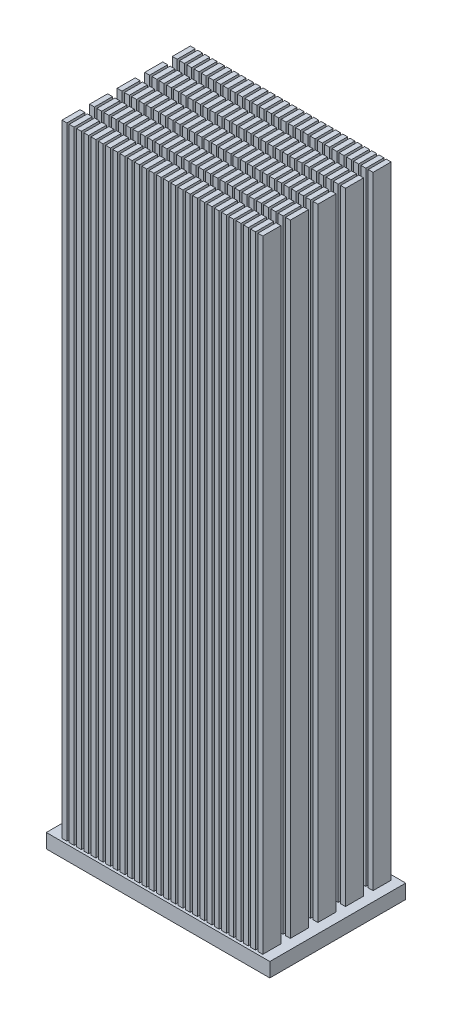
from build123d import *

# Parameters (mm, degrees)
SKETCH1_W           = 78.24
SKETCH1_H           = 47.57
BOSS_EXTRUDE1_DEPTH = 5
SKETCH2_W           = 1.704022388
SKETCH2_H           = 6.329226012
BOSS_EXTRUDE2_DEPTH = 222.758


with BuildPart() as part:
    # Sketch1 → Boss-Extrude1 (new body)
    with BuildSketch(Plane(origin=(0, 0, 0), x_dir=(1, 0, 0), z_dir=(0, 1, 0))):
        Rectangle(SKETCH1_W, SKETCH1_H)
    extrude(amount=BOSS_EXTRUDE1_DEPTH)

    # Sketch2 → Boss-Extrude2 (add)
    with BuildSketch(Plane(origin=(0, 0, 0), x_dir=(1, 0, 0), z_dir=(0, 1, 0))):
        with Locations((-33.715300105, 18.926820095)):
            Rectangle(SKETCH2_W, SKETCH2_H)
        with Locations((-31.175300105, 18.926820095)):
            Rectangle(SKETCH2_W, SKETCH2_H)
        with Locations((-28.635300105, 18.926820095)):
            Rectangle(SKETCH2_W, SKETCH2_H)
        with Locations((-26.095300105, 18.926820095)):
            Rectangle(SKETCH2_W, SKETCH2_H)
        with Locations((-23.555300105, 18.926820095)):
            Rectangle(SKETCH2_W, SKETCH2_H)
        with Locations((-21.015300105, 18.926820095)):
            Rectangle(SKETCH2_W, SKETCH2_H)
        with Locations((-18.475300105, 18.926820095)):
            Rectangle(SKETCH2_W, SKETCH2_H)
        with Locations((-15.935300105, 18.926820095)):
            Rectangle(SKETCH2_W, SKETCH2_H)
        with Locations((-13.395300105, 18.926820095)):
            Rectangle(SKETCH2_W, SKETCH2_H)
        with Locations((-10.855300105, 18.926820095)):
            Rectangle(SKETCH2_W, SKETCH2_H)
        with Locations((-8.315300105, 18.926820095)):
            Rectangle(SKETCH2_W, SKETCH2_H)
        with Locations((-5.775300105, 18.926820095)):
            Rectangle(SKETCH2_W, SKETCH2_H)
        with Locations((-3.235300105, 18.926820095)):
            Rectangle(SKETCH2_W, SKETCH2_H)
        with Locations((-0.695300105, 18.926820095)):
            Rectangle(SKETCH2_W, SKETCH2_H)
        with Locations((1.844699895, 18.926820095)):
            Rectangle(SKETCH2_W, SKETCH2_H)
        with Locations((4.384699895, 18.926820095)):
            Rectangle(SKETCH2_W, SKETCH2_H)
        with Locations((6.924699895, 18.926820095)):
            Rectangle(SKETCH2_W, SKETCH2_H)
        with Locations((9.464699895, 18.926820095)):
            Rectangle(SKETCH2_W, SKETCH2_H)
        with Locations((12.004699895, 18.926820095)):
            Rectangle(SKETCH2_W, SKETCH2_H)
        with Locations((14.544699895, 18.926820095)):
            Rectangle(SKETCH2_W, SKETCH2_H)
        with Locations((17.084699895, 18.926820095)):
            Rectangle(SKETCH2_W, SKETCH2_H)
        with Locations((19.624699895, 18.926820095)):
            Rectangle(SKETCH2_W, SKETCH2_H)
        with Locations((22.164699895, 18.926820095)):
            Rectangle(SKETCH2_W, SKETCH2_H)
        with Locations((24.704699895, 18.926820095)):
            Rectangle(SKETCH2_W, SKETCH2_H)
        with Locations((27.244699895, 18.926820095)):
            Rectangle(SKETCH2_W, SKETCH2_H)
        with Locations((29.784699895, 18.926820095)):
            Rectangle(SKETCH2_W, SKETCH2_H)
        with Locations((32.324699895, 18.926820095)):
            Rectangle(SKETCH2_W, SKETCH2_H)
        with Locations((34.864699895, 18.926820095)):
            Rectangle(SKETCH2_W, SKETCH2_H)
        with Locations((-31.175300105, 9.274820095)):
            Rectangle(SKETCH2_W, SKETCH2_H)
        with Locations((-28.635300105, 9.274820095)):
            Rectangle(SKETCH2_W, SKETCH2_H)
        with Locations((-26.095300105, 9.274820095)):
            Rectangle(SKETCH2_W, SKETCH2_H)
        with Locations((-23.555300105, 9.274820095)):
            Rectangle(SKETCH2_W, SKETCH2_H)
        with Locations((-21.015300105, 9.274820095)):
            Rectangle(SKETCH2_W, SKETCH2_H)
        with Locations((-18.475300105, 9.274820095)):
            Rectangle(SKETCH2_W, SKETCH2_H)
        with Locations((-15.935300105, 9.274820095)):
            Rectangle(SKETCH2_W, SKETCH2_H)
        with Locations((-13.395300105, 9.274820095)):
            Rectangle(SKETCH2_W, SKETCH2_H)
        with Locations((-10.855300105, 9.274820095)):
            Rectangle(SKETCH2_W, SKETCH2_H)
        with Locations((-8.315300105, 9.274820095)):
            Rectangle(SKETCH2_W, SKETCH2_H)
        with Locations((-5.775300105, 9.274820095)):
            Rectangle(SKETCH2_W, SKETCH2_H)
        with Locations((-3.235300105, 9.274820095)):
            Rectangle(SKETCH2_W, SKETCH2_H)
        with Locations((-0.695300105, 9.274820095)):
            Rectangle(SKETCH2_W, SKETCH2_H)
        with Locations((1.844699895, 9.274820095)):
            Rectangle(SKETCH2_W, SKETCH2_H)
        with Locations((4.384699895, 9.274820095)):
            Rectangle(SKETCH2_W, SKETCH2_H)
        with Locations((6.924699895, 9.274820095)):
            Rectangle(SKETCH2_W, SKETCH2_H)
        with Locations((9.464699895, 9.274820095)):
            Rectangle(SKETCH2_W, SKETCH2_H)
        with Locations((12.004699895, 9.274820095)):
            Rectangle(SKETCH2_W, SKETCH2_H)
        with Locations((14.544699895, 9.274820095)):
            Rectangle(SKETCH2_W, SKETCH2_H)
        with Locations((17.084699895, 9.274820095)):
            Rectangle(SKETCH2_W, SKETCH2_H)
        with Locations((19.624699895, 9.274820095)):
            Rectangle(SKETCH2_W, SKETCH2_H)
        with Locations((22.164699895, 9.274820095)):
            Rectangle(SKETCH2_W, SKETCH2_H)
        with Locations((24.704699895, 9.274820095)):
            Rectangle(SKETCH2_W, SKETCH2_H)
        with Locations((27.244699895, 9.274820095)):
            Rectangle(SKETCH2_W, SKETCH2_H)
        with Locations((29.784699895, 9.274820095)):
            Rectangle(SKETCH2_W, SKETCH2_H)
        with Locations((32.324699895, 9.274820095)):
            Rectangle(SKETCH2_W, SKETCH2_H)
        with Locations((34.864699895, 9.274820095)):
            Rectangle(SKETCH2_W, SKETCH2_H)
        with Locations((-31.175300105, -0.377179905)):
            Rectangle(SKETCH2_W, SKETCH2_H)
        with Locations((-28.635300105, -0.377179905)):
            Rectangle(SKETCH2_W, SKETCH2_H)
        with Locations((-26.095300105, -0.377179905)):
            Rectangle(SKETCH2_W, SKETCH2_H)
        with Locations((-23.555300105, -0.377179905)):
            Rectangle(SKETCH2_W, SKETCH2_H)
        with Locations((-21.015300105, -0.377179905)):
            Rectangle(SKETCH2_W, SKETCH2_H)
        with Locations((-18.475300105, -0.377179905)):
            Rectangle(SKETCH2_W, SKETCH2_H)
        with Locations((-15.935300105, -0.377179905)):
            Rectangle(SKETCH2_W, SKETCH2_H)
        with Locations((-13.395300105, -0.377179905)):
            Rectangle(SKETCH2_W, SKETCH2_H)
        with Locations((-10.855300105, -0.377179905)):
            Rectangle(SKETCH2_W, SKETCH2_H)
        with Locations((-8.315300105, -0.377179905)):
            Rectangle(SKETCH2_W, SKETCH2_H)
        with Locations((-5.775300105, -0.377179905)):
            Rectangle(SKETCH2_W, SKETCH2_H)
        with Locations((-3.235300105, -0.377179905)):
            Rectangle(SKETCH2_W, SKETCH2_H)
        with Locations((-0.695300105, -0.377179905)):
            Rectangle(SKETCH2_W, SKETCH2_H)
        with Locations((1.844699895, -0.377179905)):
            Rectangle(SKETCH2_W, SKETCH2_H)
        with Locations((4.384699895, -0.377179905)):
            Rectangle(SKETCH2_W, SKETCH2_H)
        with Locations((6.924699895, -0.377179905)):
            Rectangle(SKETCH2_W, SKETCH2_H)
        with Locations((9.464699895, -0.377179905)):
            Rectangle(SKETCH2_W, SKETCH2_H)
        with Locations((12.004699895, -0.377179905)):
            Rectangle(SKETCH2_W, SKETCH2_H)
        with Locations((14.544699895, -0.377179905)):
            Rectangle(SKETCH2_W, SKETCH2_H)
        with Locations((17.084699895, -0.377179905)):
            Rectangle(SKETCH2_W, SKETCH2_H)
        with Locations((19.624699895, -0.377179905)):
            Rectangle(SKETCH2_W, SKETCH2_H)
        with Locations((22.164699895, -0.377179905)):
            Rectangle(SKETCH2_W, SKETCH2_H)
        with Locations((24.704699895, -0.377179905)):
            Rectangle(SKETCH2_W, SKETCH2_H)
        with Locations((27.244699895, -0.377179905)):
            Rectangle(SKETCH2_W, SKETCH2_H)
        with Locations((29.784699895, -0.377179905)):
            Rectangle(SKETCH2_W, SKETCH2_H)
        with Locations((32.324699895, -0.377179905)):
            Rectangle(SKETCH2_W, SKETCH2_H)
        with Locations((34.864699895, -0.377179905)):
            Rectangle(SKETCH2_W, SKETCH2_H)
        with Locations((-31.175300105, -10.029179905)):
            Rectangle(SKETCH2_W, SKETCH2_H)
        with Locations((-28.635300105, -10.029179905)):
            Rectangle(SKETCH2_W, SKETCH2_H)
        with Locations((-26.095300105, -10.029179905)):
            Rectangle(SKETCH2_W, SKETCH2_H)
        with Locations((-23.555300105, -10.029179905)):
            Rectangle(SKETCH2_W, SKETCH2_H)
        with Locations((-21.015300105, -10.029179905)):
            Rectangle(SKETCH2_W, SKETCH2_H)
        with Locations((-18.475300105, -10.029179905)):
            Rectangle(SKETCH2_W, SKETCH2_H)
        with Locations((-15.935300105, -10.029179905)):
            Rectangle(SKETCH2_W, SKETCH2_H)
        with Locations((-13.395300105, -10.029179905)):
            Rectangle(SKETCH2_W, SKETCH2_H)
        with Locations((-10.855300105, -10.029179905)):
            Rectangle(SKETCH2_W, SKETCH2_H)
        with Locations((-8.315300105, -10.029179905)):
            Rectangle(SKETCH2_W, SKETCH2_H)
        with Locations((-5.775300105, -10.029179905)):
            Rectangle(SKETCH2_W, SKETCH2_H)
        with Locations((-3.235300105, -10.029179905)):
            Rectangle(SKETCH2_W, SKETCH2_H)
        with Locations((-0.695300105, -10.029179905)):
            Rectangle(SKETCH2_W, SKETCH2_H)
        with Locations((1.844699895, -10.029179905)):
            Rectangle(SKETCH2_W, SKETCH2_H)
        with Locations((4.384699895, -10.029179905)):
            Rectangle(SKETCH2_W, SKETCH2_H)
        with Locations((6.924699895, -10.029179905)):
            Rectangle(SKETCH2_W, SKETCH2_H)
        with Locations((9.464699895, -10.029179905)):
            Rectangle(SKETCH2_W, SKETCH2_H)
        with Locations((12.004699895, -10.029179905)):
            Rectangle(SKETCH2_W, SKETCH2_H)
        with Locations((14.544699895, -10.029179905)):
            Rectangle(SKETCH2_W, SKETCH2_H)
        with Locations((17.084699895, -10.029179905)):
            Rectangle(SKETCH2_W, SKETCH2_H)
        with Locations((19.624699895, -10.029179905)):
            Rectangle(SKETCH2_W, SKETCH2_H)
        with Locations((22.164699895, -10.029179905)):
            Rectangle(SKETCH2_W, SKETCH2_H)
        with Locations((24.704699895, -10.029179905)):
            Rectangle(SKETCH2_W, SKETCH2_H)
        with Locations((27.244699895, -10.029179905)):
            Rectangle(SKETCH2_W, SKETCH2_H)
        with Locations((29.784699895, -10.029179905)):
            Rectangle(SKETCH2_W, SKETCH2_H)
        with Locations((32.324699895, -10.029179905)):
            Rectangle(SKETCH2_W, SKETCH2_H)
        with Locations((34.864699895, -10.029179905)):
            Rectangle(SKETCH2_W, SKETCH2_H)
        with Locations((-31.175300105, -19.681179905)):
            Rectangle(SKETCH2_W, SKETCH2_H)
        with Locations((-28.635300105, -19.681179905)):
            Rectangle(SKETCH2_W, SKETCH2_H)
        with Locations((-26.095300105, -19.681179905)):
            Rectangle(SKETCH2_W, SKETCH2_H)
        with Locations((-23.555300105, -19.681179905)):
            Rectangle(SKETCH2_W, SKETCH2_H)
        with Locations((-21.015300105, -19.681179905)):
            Rectangle(SKETCH2_W, SKETCH2_H)
        with Locations((-18.475300105, -19.681179905)):
            Rectangle(SKETCH2_W, SKETCH2_H)
        with Locations((-15.935300105, -19.681179905)):
            Rectangle(SKETCH2_W, SKETCH2_H)
        with Locations((-13.395300105, -19.681179905)):
            Rectangle(SKETCH2_W, SKETCH2_H)
        with Locations((-10.855300105, -19.681179905)):
            Rectangle(SKETCH2_W, SKETCH2_H)
        with Locations((-8.315300105, -19.681179905)):
            Rectangle(SKETCH2_W, SKETCH2_H)
        with Locations((-5.775300105, -19.681179905)):
            Rectangle(SKETCH2_W, SKETCH2_H)
        with Locations((-3.235300105, -19.681179905)):
            Rectangle(SKETCH2_W, SKETCH2_H)
        with Locations((-0.695300105, -19.681179905)):
            Rectangle(SKETCH2_W, SKETCH2_H)
        with Locations((1.844699895, -19.681179905)):
            Rectangle(SKETCH2_W, SKETCH2_H)
        with Locations((4.384699895, -19.681179905)):
            Rectangle(SKETCH2_W, SKETCH2_H)
        with Locations((6.924699895, -19.681179905)):
            Rectangle(SKETCH2_W, SKETCH2_H)
        with Locations((9.464699895, -19.681179905)):
            Rectangle(SKETCH2_W, SKETCH2_H)
        with Locations((12.004699895, -19.681179905)):
            Rectangle(SKETCH2_W, SKETCH2_H)
        with Locations((14.544699895, -19.681179905)):
            Rectangle(SKETCH2_W, SKETCH2_H)
        with Locations((17.084699895, -19.681179905)):
            Rectangle(SKETCH2_W, SKETCH2_H)
        with Locations((19.624699895, -19.681179905)):
            Rectangle(SKETCH2_W, SKETCH2_H)
        with Locations((22.164699895, -19.681179905)):
            Rectangle(SKETCH2_W, SKETCH2_H)
        with Locations((24.704699895, -19.681179905)):
            Rectangle(SKETCH2_W, SKETCH2_H)
        with Locations((27.244699895, -19.681179905)):
            Rectangle(SKETCH2_W, SKETCH2_H)
        with Locations((29.784699895, -19.681179905)):
            Rectangle(SKETCH2_W, SKETCH2_H)
        with Locations((32.324699895, -19.681179905)):
            Rectangle(SKETCH2_W, SKETCH2_H)
        with Locations((34.864699895, -19.681179905)):
            Rectangle(SKETCH2_W, SKETCH2_H)
        with Locations((-33.715300105, 9.274820095)):
            Rectangle(SKETCH2_W, SKETCH2_H)
        with Locations((-33.715300105, -0.377179905)):
            Rectangle(SKETCH2_W, SKETCH2_H)
        with Locations((-33.715300105, -10.029179905)):
            Rectangle(SKETCH2_W, SKETCH2_H)
        with Locations((-33.715300105, -19.681179905)):
            Rectangle(SKETCH2_W, SKETCH2_H)
    extrude(amount=BOSS_EXTRUDE2_DEPTH)


solid = part.part
